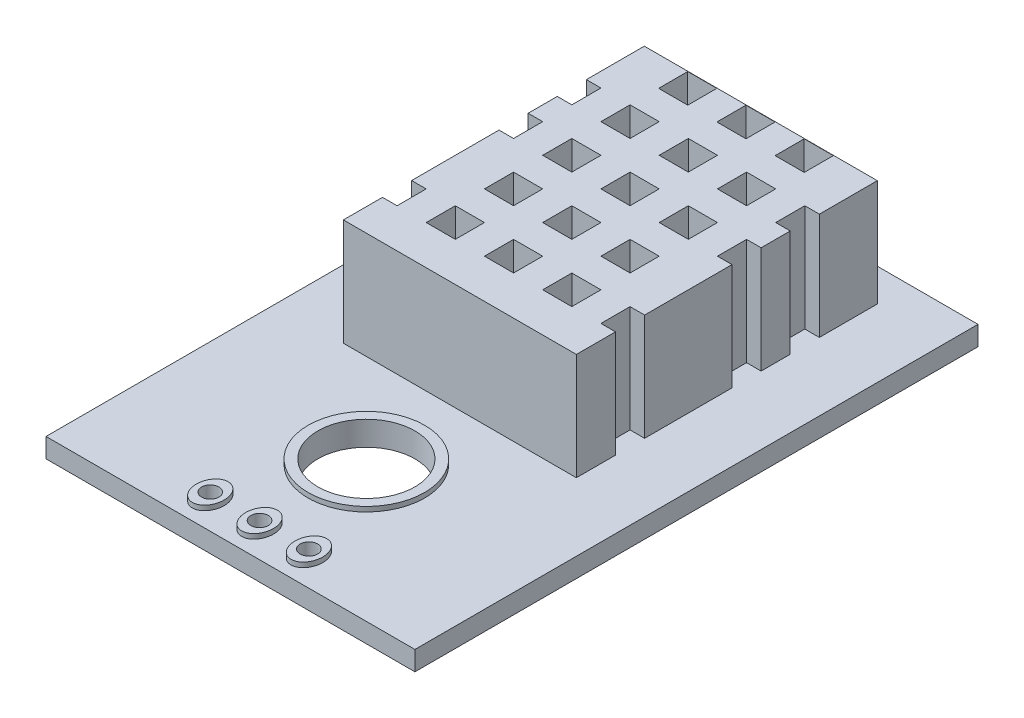
from build123d import *

# Parameters (mm, degrees)
SKETCH1_W               = 19
SKETCH1_H               = 29
SKETCH1_R               = 2.5
BOSS_EXTRUDE2_DEPTH     = 1
SKETCH3_R               = 3
SKETCH3_R_2             = 2.5
SKETCH3_RX              = 0.922092895
SKETCH3_RY              = 0.713508325
SKETCH3_R_3             = 0.45
BOSS_EXTRUDE3_DEPTH     = 0.25
SKETCH4_R               = 0.45
CUT_EXTRUDE1_DEPTH      = 1.25
CUT_EXTRUDE1_DEPTH_BACK = 2
SKETCH5_W               = 12
SKETCH5_H               = 15.5
BOSS_EXTRUDE4_DEPTH     = 5.5
SKETCH7_W               = 1.5
SKETCH7_H               = 1.5
SKETCH7_W_2             = 0.75
CUT_EXTRUDE2_DEPTH      = 6


with BuildPart() as part:
    # Sketch1 → Boss-Extrude2 (new body)
    with BuildSketch(Plane(origin=(0, 0, 0), x_dir=(1, 0, 0), z_dir=(0, 1, 0))):
        Rectangle(SKETCH1_W, SKETCH1_H)
        with Locations((0, -7.5)):
            Circle(SKETCH1_R, mode=Mode.SUBTRACT)
    extrude(amount=-BOSS_EXTRUDE2_DEPTH)

    # Sketch3 → Boss-Extrude3 (add)
    with BuildSketch(Plane(origin=(0, 0, 0), x_dir=(1, 0, 0), z_dir=(0, 1, 0))):
        with Locations((0, -7.5)):
            Circle(SKETCH3_R)
        with Locations((0, -7.5)):
            Circle(SKETCH3_R_2, mode=Mode.SUBTRACT)
        with Locations(Location((0, -13), (0, 0, -90))):
            Ellipse(SKETCH3_RX, SKETCH3_RY)
        with Locations((0, -13)):
            Circle(SKETCH3_R_3, mode=Mode.SUBTRACT)
        with Locations(Location((2.54, -13), (0, 0, -90))):
            Ellipse(SKETCH3_RX, SKETCH3_RY)
        with Locations((2.54, -13)):
            Circle(SKETCH3_R_3, mode=Mode.SUBTRACT)
        with Locations(Location((-2.54, -13), (0, 0, -90))):
            Ellipse(SKETCH3_RX, SKETCH3_RY)
        with Locations((-2.54, -13)):
            Circle(SKETCH3_R_3, mode=Mode.SUBTRACT)
    extrude(amount=BOSS_EXTRUDE3_DEPTH)

    # Sketch4 → Cut-Extrude1 (cut, two sides)
    with BuildSketch(Plane(origin=(0, 0, 0), x_dir=(1, 0, 0), z_dir=(0, 1, 0))) as cut_extrude1_sk:
        with Locations((-2.54, -13)):
            Circle(SKETCH4_R)
        with Locations((0, -13)):
            Circle(SKETCH4_R)
        with Locations((2.54, -13)):
            Circle(SKETCH4_R)
    extrude(amount=CUT_EXTRUDE1_DEPTH, mode=Mode.SUBTRACT)
    extrude(cut_extrude1_sk.sketch, amount=-CUT_EXTRUDE1_DEPTH_BACK, mode=Mode.SUBTRACT)

    # Sketch5 → Boss-Extrude4 (add)
    with BuildSketch(Plane(origin=(0, 0, 0), x_dir=(1, 0, 0), z_dir=(0, 1, 0))):
        with Locations((0, 5.065615618)):
            Rectangle(SKETCH5_W, SKETCH5_H)
    extrude(amount=BOSS_EXTRUDE4_DEPTH)

    # Sketch7 → Cut-Extrude2 (cut)
    with BuildSketch(Plane(origin=(0, 0, 0), x_dir=(1, 0, 0), z_dir=(0, 1, 0))):
        with Locations((-3, 12.050904241)):
            Rectangle(SKETCH7_W, SKETCH7_H)
        with Locations((0, 12.050904241)):
            Rectangle(SKETCH7_W, SKETCH7_H)
        with Locations((3, 12.050904241)):
            Rectangle(SKETCH7_W, SKETCH7_H)
        with Locations((-3, 9.080326995)):
            Rectangle(SKETCH7_W, SKETCH7_H)
        with Locations((3, 9.080326995)):
            Rectangle(SKETCH7_W, SKETCH7_H)
        with Locations((0, 9.080326995)):
            Rectangle(SKETCH7_W, SKETCH7_H)
        with Locations((-3, 6.080326995)):
            Rectangle(SKETCH7_W, SKETCH7_H)
        with Locations((0, 6.080326995)):
            Rectangle(SKETCH7_W, SKETCH7_H)
        with Locations((3, 6.080326995)):
            Rectangle(SKETCH7_W, SKETCH7_H)
        with Locations((-3, 3.080326995)):
            Rectangle(SKETCH7_W, SKETCH7_H)
        with Locations((3, 3.080326995)):
            Rectangle(SKETCH7_W, SKETCH7_H)
        with Locations((0, 3.080326995)):
            Rectangle(SKETCH7_W, SKETCH7_H)
        with Locations((-3, 0.080326995)):
            Rectangle(SKETCH7_W, SKETCH7_H)
        with Locations((0, 0.080326995)):
            Rectangle(SKETCH7_W, SKETCH7_H)
        with Locations((3, 0.080326995)):
            Rectangle(SKETCH7_W, SKETCH7_H)
        with Locations((5.625, 6.080326995)):
            Rectangle(SKETCH7_W_2, SKETCH7_H)
        with Locations((-5.625, 6.080326995)):
            Rectangle(SKETCH7_W_2, SKETCH7_H)
        with Locations((5.625, 9.080326995)):
            Rectangle(SKETCH7_W_2, SKETCH7_H)
        with Locations((-5.625, 9.080326995)):
            Rectangle(SKETCH7_W_2, SKETCH7_H)
        with Locations((5.625, 0.080326995)):
            Rectangle(SKETCH7_W_2, SKETCH7_H)
        with Locations((-5.625, 0.080326995)):
            Rectangle(SKETCH7_W_2, SKETCH7_H)
    extrude(amount=CUT_EXTRUDE2_DEPTH, mode=Mode.SUBTRACT)


solid = part.part
